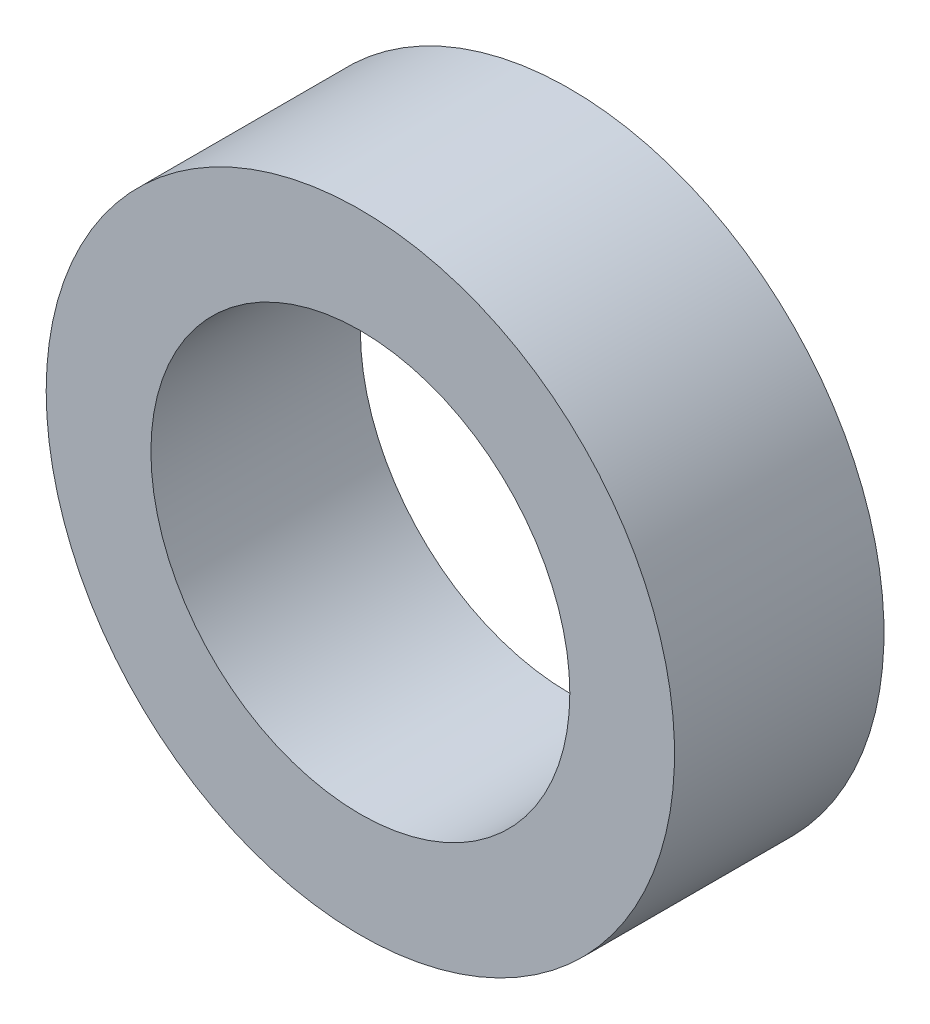
from build123d import *

# Parameters (mm, degrees)
EXTRUDE_1_DEPTH = 10


with BuildPart() as part:
    # Эскиз1 → Вытянуть-Тонкостенный1 (new body)
    with BuildSketch(Plane.XY):
        with BuildLine():
            ThreePointArc((-40, -5), (-50.606601718, -0.606601718), (-55, 10))
            ThreePointArc((-55, 10), (-29.393398282, 20.606601718), (-40, -5))
        make_face()
        with BuildLine():
            ThreePointArc((-40, 0), (-47.071067812, 2.928932188), (-50, 10))
            ThreePointArc((-50, 10), (-32.928932188, 17.071067812), (-40, 0))
        make_face(mode=Mode.SUBTRACT)
    extrude(amount=EXTRUDE_1_DEPTH)


solid = part.part
